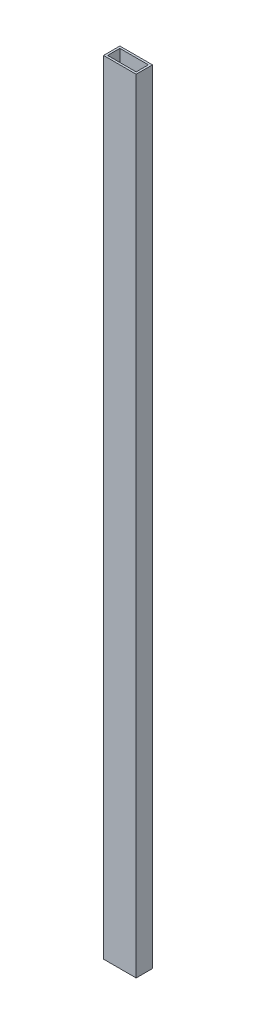
from build123d import *

# Parameters (mm, degrees)
SKETCH1_W           = 50.8
SKETCH1_H           = 25.4
SKETCH1_W_2         = 44.45
SKETCH1_H_2         = 19.05
BOSS_EXTRUDE1_DEPTH = 1219.2


with BuildPart() as part:
    # Sketch1 → Boss-Extrude1 (new body)
    with BuildSketch(Plane(origin=(0, 0, 0), x_dir=(1, 0, 0), z_dir=(0, 1, 0))):
        Rectangle(SKETCH1_W, SKETCH1_H)
        Rectangle(SKETCH1_W_2, SKETCH1_H_2, mode=Mode.SUBTRACT)
    extrude(amount=BOSS_EXTRUDE1_DEPTH)


solid = part.part
